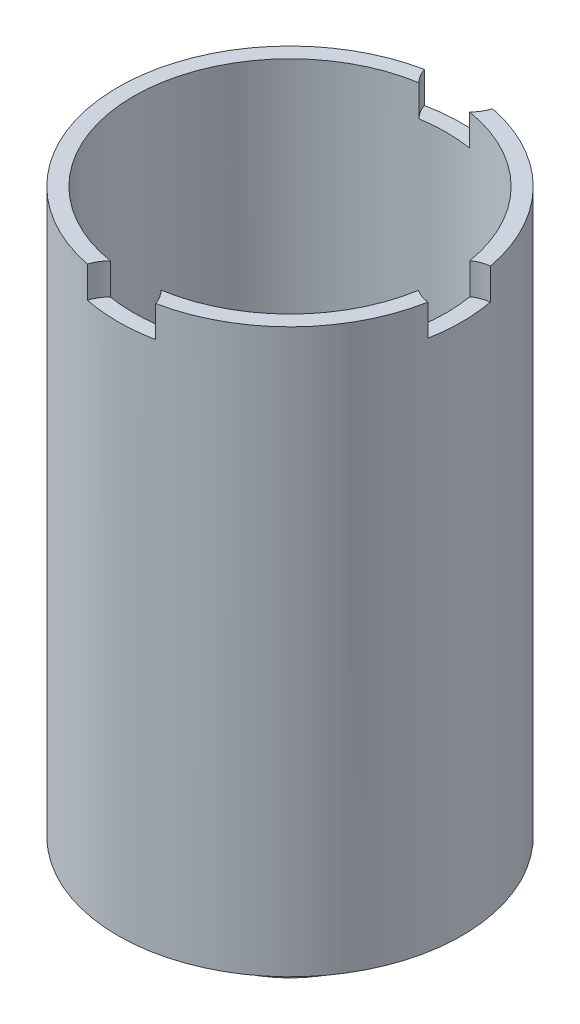
from build123d import *

# Parameters (mm, degrees)
ESQUISSE1_R                  = 5.5
BASE_EXTRUSION_DEPTH         = 18
ESQUISSE2_R                  = 3
BOSS_EXTRU_1_DEPTH           = 1.8
COQUE1_T                     = -0.5
ESQUISSE3_R                  = 1.25
ENL_V_MAT_EXTRU_1_DEPTH      = 22.272987566
ESQUISSE4_R                  = 1
ESQUISSE4_R_2                = 1.15
ENL_V_MAT_EXTRU_2_DEPTH      = 1
ENL_V_MAT_EXTRU_3_REACH      = 21.609
ESQUISSE5_R                  = 0.5
R_P_TITION_CIRCULAIRE1_COUNT = 3
R_P_TITION_CIRCULAIRE1_ANGLE = 180


with BuildPart() as part:
    # Esquisse1 → Base-Extrusion (new body)
    with BuildSketch(Plane(origin=(0, 0, 0), x_dir=(1, 0, 0), z_dir=(0, 1, 0))):
        with Locations(Location((0, 0, 0), (0, 0, 270))):
            Circle(ESQUISSE1_R)
    extrude(amount=-BASE_EXTRUSION_DEPTH)

    # Esquisse2 → Boss.-Extru.1 (add)
    with BuildSketch(Plane.XZ.offset(18)):
        with Locations(Location((0, 0, 0), (0, 0, 90))):
            Circle(ESQUISSE2_R)
    extrude(amount=BOSS_EXTRU_1_DEPTH)

    # Coque1
    coque1_openings = [part.faces().sort_by_distance(p)[0] for p in [
        (0, 0, 0),
    ]]
    offset(amount=COQUE1_T, openings=coque1_openings, kind=Kind.INTERSECTION)

    # Esquisse3 → Enlèv. mat.-Extru.1 (cut, through all)
    with BuildSketch(Plane.XZ.offset(19.8)):
        with Locations(Location((0, 0, 0), (0, 0, 270))):
            Circle(ESQUISSE3_R)
    extrude(amount=-ENL_V_MAT_EXTRU_1_DEPTH, mode=Mode.SUBTRACT)

    # Esquisse4 → Enlèv. mat.-Extru.2 (cut)
    with BuildSketch(Plane.XZ):
        with Locations((5.5, 0)):
            Circle(ESQUISSE4_R)
        with Locations((0, -5.75)):
            Circle(ESQUISSE4_R_2)
        with Locations((0, 5.75)):
            Circle(ESQUISSE4_R_2)
    extrude(amount=ENL_V_MAT_EXTRU_2_DEPTH, mode=Mode.SUBTRACT)

    # Esquisse5 → Enlèv. mat.-Extru.3 (cut, up to next)
    with BuildSketch(Plane.XZ.offset(18), mode=Mode.PRIVATE) as enl_v_mat_extru_3_sk1:
        with Locations(Location((0, 4.17675231, 0), (0, 0, 270))):
            Circle(ESQUISSE5_R)
    enl_v_mat_extru_3_tool1 = extrude(enl_v_mat_extru_3_sk1.sketch, amount=-ENL_V_MAT_EXTRU_3_REACH, mode=Mode.PRIVATE) & part.part
    enl_v_mat_extru_3 = enl_v_mat_extru_3_tool1.solids().sort_by_distance((0, -18, 4.176752))[0]
    add(enl_v_mat_extru_3, mode=Mode.SUBTRACT)

    # Répétition circulaire1: Enlèv. mat.-Extru.3 ×3 about axis
    r_p_tition_circulaire1_axis = Axis((0, 0, 0), (0, 1, 0))
    for i in range(1, R_P_TITION_CIRCULAIRE1_COUNT):
        add(enl_v_mat_extru_3.rotate(r_p_tition_circulaire1_axis, i * R_P_TITION_CIRCULAIRE1_ANGLE / (R_P_TITION_CIRCULAIRE1_COUNT - 1)), mode=Mode.SUBTRACT)


solid = part.part
